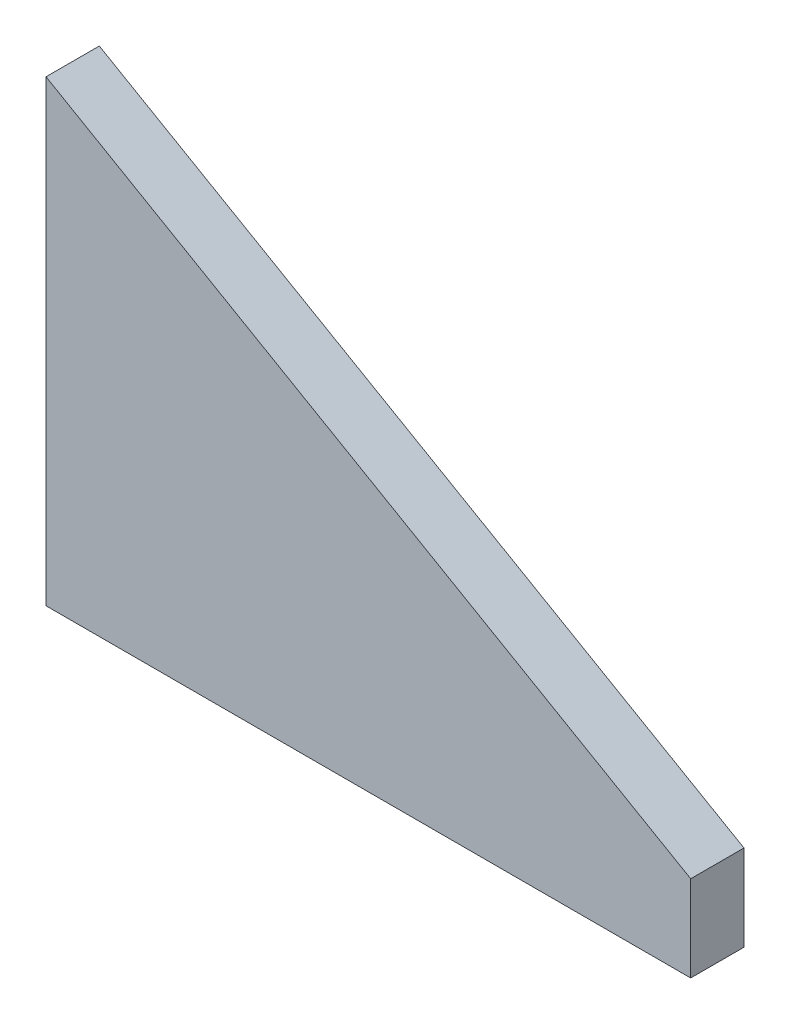
from build123d import *

# Parameters (mm, degrees)
EXTRUDE1_DEPTH = 0.7874


with BuildPart() as part:
    # Sketch1 → Extrude1 (new body, symmetric)
    with BuildSketch(Plane.XY):
        Polygon((-9.525, 4.0132), (9.525, -6.985), (9.525, -9.525), (-9.525, -9.525), (-9.525, -6.985), align=None)
    extrude(amount=EXTRUDE1_DEPTH, both=True)


solid = part.part
